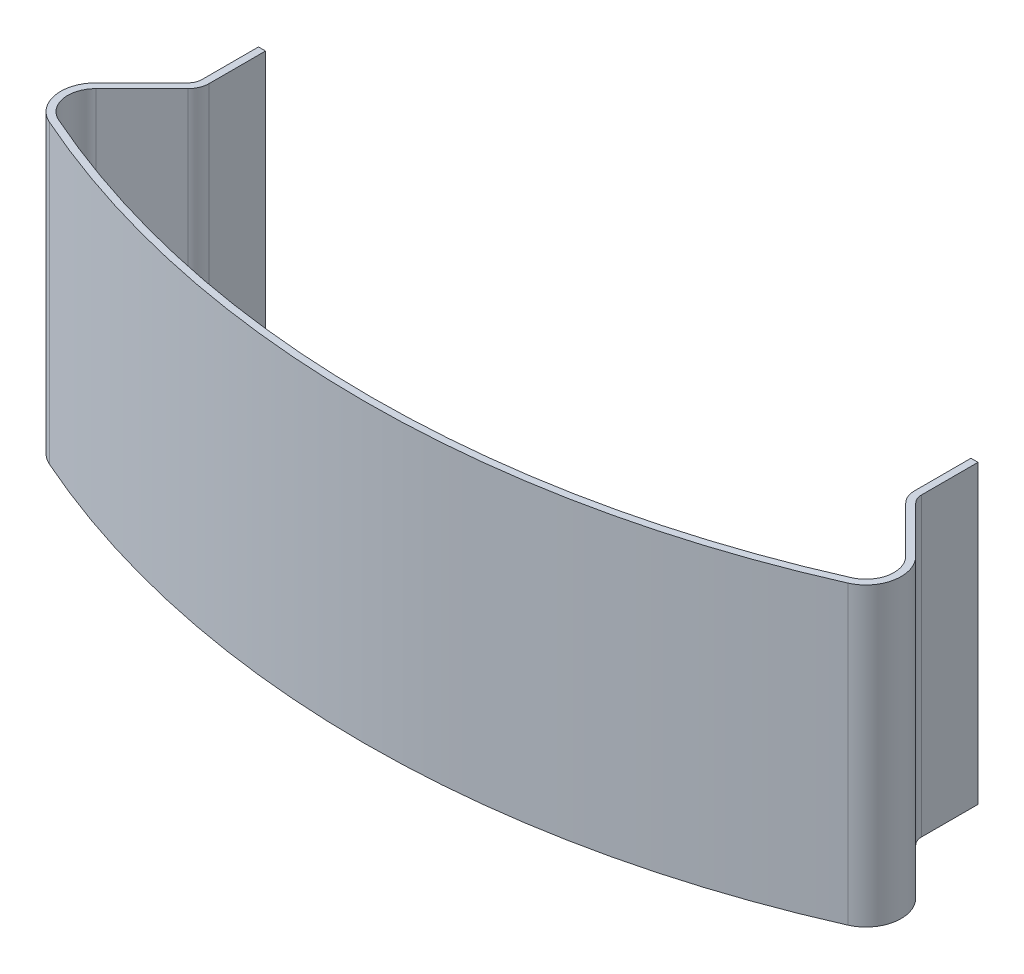
from build123d import *

# Parameters (mm, degrees)
BOSS_EXTRUDE1_DEPTH = 42


with BuildPart() as part:
    # Sketch1 → Boss-Extrude1 (new body)
    with BuildSketch(Plane(origin=(0, 0, 0), x_dir=(1, 0, 0), z_dir=(0, 1, 0))):
        with BuildLine():
            Line((-58.112270696, -119.940697821), (-51.585786438, -113.414213562))
            ThreePointArc((-51.585786438, -113.414213562), (-51.152240935, -112.765366865), (-51, -112))
            Line((-51, -112), (-51, -104))
            Line((-51, -104), (-50, -104))
            Line((-50, -104), (-50, -112))
            ThreePointArc((-50, -112), (-50.228361402, -113.148050297), (-50.878679656, -114.121320344))
            Line((-50.878679656, -114.121320344), (-57.405163915, -120.647804602))
            ThreePointArc((-57.405163915, -120.647804602), (-58.508770183, -124.210475144), (-56.193825287, -127.134786741))
            ThreePointArc((-56.193825287, -127.134786741), (0, -139), (56.193825287, -127.134786741))
            ThreePointArc((56.193825287, -127.134786741), (58.508770183, -124.210475144), (57.405163915, -120.647804602))
            Line((57.405163915, -120.647804602), (50.878679656, -114.121320344))
            ThreePointArc((50.878679656, -114.121320344), (50.228361402, -113.148050297), (50, -112))
            Line((50, -112), (50, -104))
            Line((50, -104), (51, -104))
            Line((51, -104), (51, -112))
            ThreePointArc((51, -112), (51.152240935, -112.765366865), (51.585786438, -113.414213562))
            Line((51.585786438, -113.414213562), (58.112270696, -119.940697821))
            ThreePointArc((58.112270696, -119.940697821), (59.491778531, -124.394035998), (56.598097412, -128.049425494))
            ThreePointArc((56.598097412, -128.049425494), (0, -140), (-56.598097412, -128.049425494))
            ThreePointArc((-56.598097412, -128.049425494), (-59.491778531, -124.394035998), (-58.112270696, -119.940697821))
        make_face()
    extrude(amount=BOSS_EXTRUDE1_DEPTH)


solid = part.part
